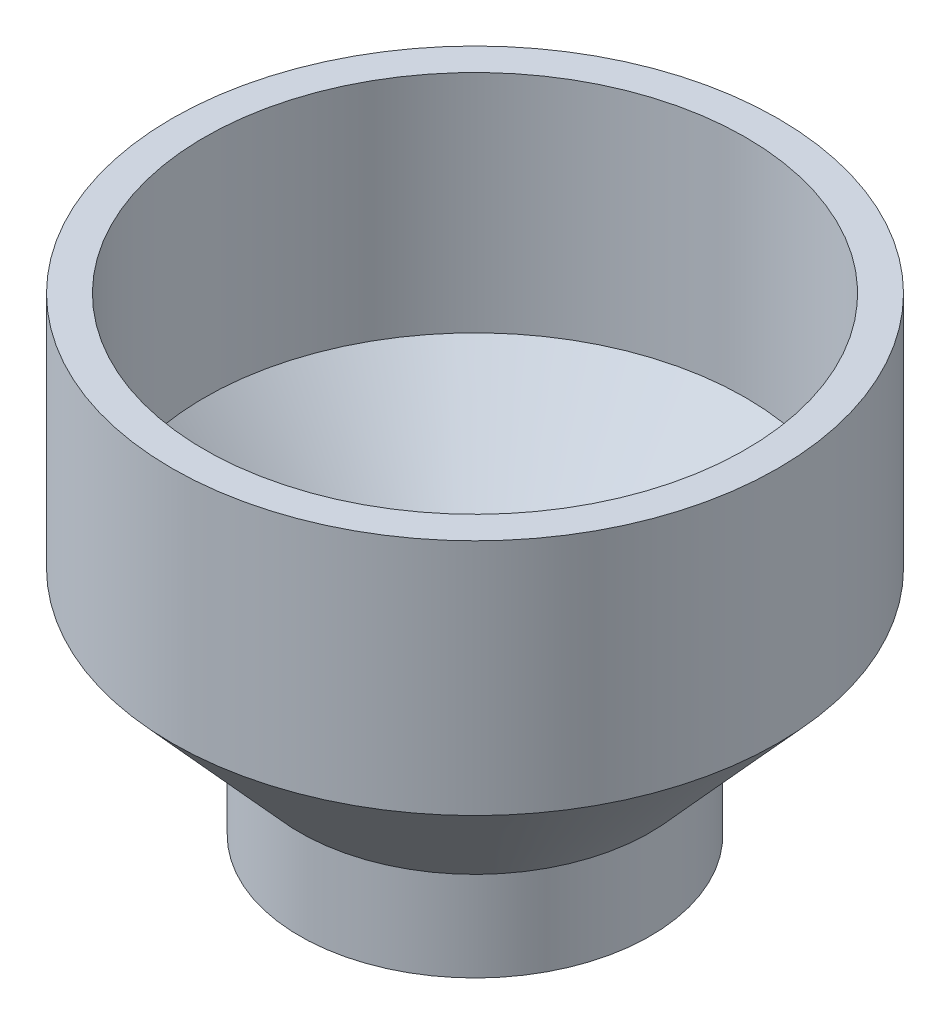
from build123d import *


with BuildPart() as part:
    # Sketch1 → Revolve-Thin1 (revolve)
    with BuildSketch(Plane.XY):
        Polygon((-57.15, 0), (-57.15, -47.625), (-30.1625, -77.47), (-30.1625, -99.06), (-37.0205, -99.06), (-37.0205, -80.110894832), (-64.008, -50.265894832), (-64.008, 0), align=None)
    revolve(axis=Axis((0, 0, 0), (0, 1, 0)))


solid = part.part
